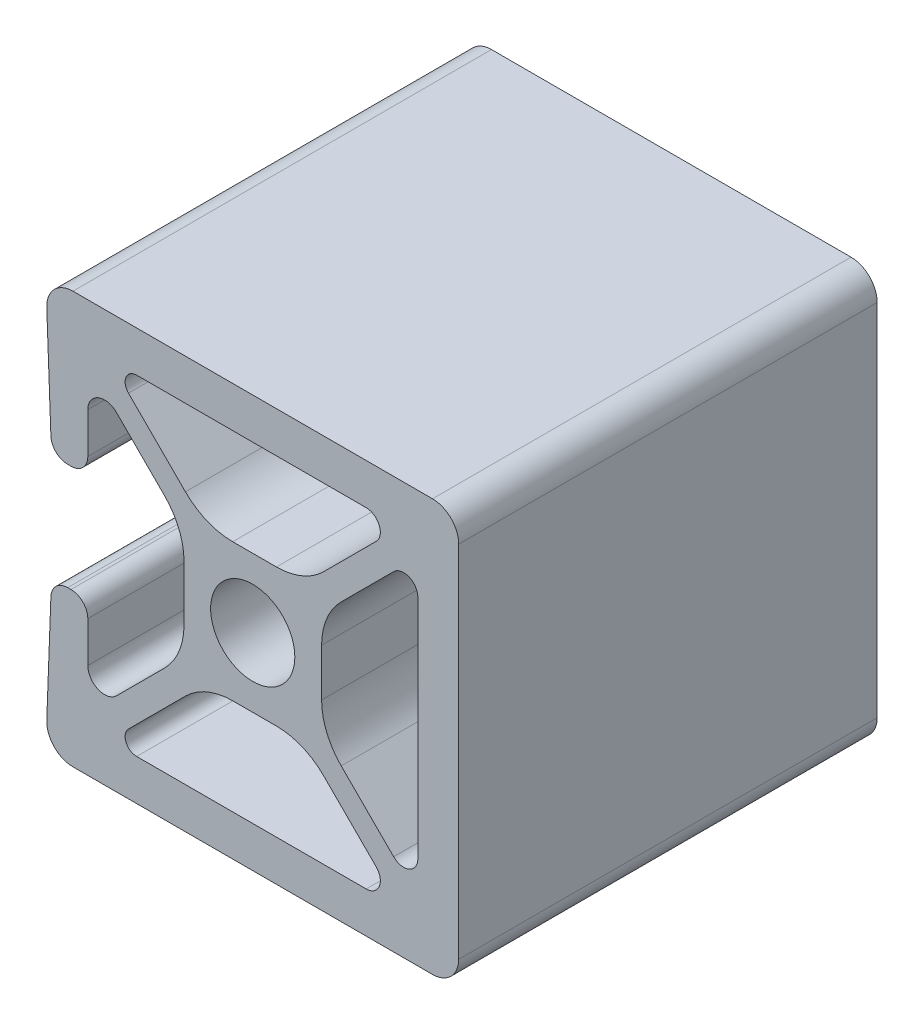
from build123d import *

# Parameters (mm, degrees)
EXTRUDE1_DEPTH = 25.4


with BuildPart() as part:
    # Sketch1 → Extrude1 (new body)
    with BuildSketch(Plane.XY):
        with BuildLine():
            Line((-8.268033791, 7.446247994), (-5.358427067, 4.536641271))
            ThreePointArc((-5.358427067, 4.536641271), (-4.478329805, 3.219482637), (-4.169280745, 1.665788092))
            Line((-4.169280745, 1.665788092), (-4.169280745, 0))
            Line((-4.169280745, 0), (-4.169280745, -1.665788092))
            ThreePointArc((-4.169280745, -1.665788092), (-4.478329805, -3.219482637), (-5.358427067, -4.536641271))
            Line((-5.358427067, -4.536641271), (-8.268033791, -7.446247994))
            ThreePointArc((-8.268033791, -7.446247994), (-9.379617585, -7.667355758), (-10.009279225, -6.72500052))
            Line((-10.009279225, -6.72500052), (-10.009279225, -4.25999656))
            ThreePointArc((-10.009279225, -4.25999656), (-10.308029711, -3.538749086), (-11.029277185, -3.2399986))
            Line((-11.029277185, -3.2399986), (-11.23000167, -3.2399986))
            ThreePointArc((-11.23000167, -3.2399986), (-11.937549497, -3.525304849), (-12.249277285, -4.221616108))
            Line((-12.249277285, -4.221616108), (-12.49887312, -10.850171322))
            ThreePointArc((-12.49887312, -10.850171322), (-12.055256326, -12.012943733), (-10.90999977, -12.49999913))
            Line((-10.90999977, -12.49999913), (0, -12.49999913))
            Line((0, -12.49999913), (10.90999977, -12.49999913))
            ThreePointArc((10.90999977, -12.49999913), (12.0342991, -12.0342991), (12.49999913, -10.90999977))
            Line((12.49999913, -10.90999977), (12.49999913, 10.90999977))
            ThreePointArc((12.49999913, 10.90999977), (12.0342991, 12.0342991), (10.90999977, 12.49999913))
            Line((10.90999977, 12.49999913), (0, 12.49999913))
            Line((0, 12.49999913), (-10.90999977, 12.49999913))
            ThreePointArc((-10.90999977, 12.49999913), (-12.055256326, 12.012943733), (-12.49887312, 10.850171322))
            Line((-12.49887312, 10.850171322), (-12.249277285, 4.221616108))
            ThreePointArc((-12.249277285, 4.221616108), (-11.937549497, 3.525304849), (-11.23000167, 3.2399986))
            Line((-11.23000167, 3.2399986), (-11.029277185, 3.2399986))
            ThreePointArc((-11.029277185, 3.2399986), (-10.308029711, 3.538749086), (-10.009279225, 4.25999656))
            Line((-10.009279225, 4.25999656), (-10.009279225, 6.72500052))
            ThreePointArc((-10.009279225, 6.72500052), (-9.379617585, 7.667355758), (-8.268033791, 7.446247994))
        make_face()
        with BuildLine():
            Line((-7.539973637, 8.825029193), (-4.084091296, 5.369146852))
            ThreePointArc((-4.084091296, 5.369146852), (-2.766932662, 4.48904959), (-1.213238118, 4.18000053))
            Line((-1.213238118, 4.18000053), (0, 4.18000053))
            Line((0, 4.18000053), (1.439511835, 4.18000053))
            ThreePointArc((1.439511835, 4.18000053), (2.993206379, 4.48904959), (4.310365013, 5.369146852))
            Line((4.310365013, 5.369146852), (7.493110816, 8.551892654))
            ThreePointArc((7.493110816, 8.551892654), (7.679535009, 9.489110364), (6.8850002, 10.02000155))
            Line((6.8850002, 10.02000155), (0, 10.02000155))
            Line((0, 10.02000155), (-7.04499988, 10.02000155))
            ThreePointArc((-7.04499988, 10.02000155), (-7.691714259, 9.587880817), (-7.539973637, 8.825029193))
        make_face(mode=Mode.SUBTRACT)
        with BuildLine():
            Line((0, -10.02000155), (-7.04499988, -10.02000155))
            ThreePointArc((-7.04499988, -10.02000155), (-7.691714259, -9.587880817), (-7.539973637, -8.825029193))
            Line((-7.539973637, -8.825029193), (-4.084091296, -5.369146852))
            ThreePointArc((-4.084091296, -5.369146852), (-2.766932662, -4.48904959), (-1.213238118, -4.18000053))
            Line((-1.213238118, -4.18000053), (0, -4.18000053))
            Line((0, -4.18000053), (1.439511835, -4.18000053))
            ThreePointArc((1.439511835, -4.18000053), (2.993206379, -4.48904959), (4.310365013, -5.369146852))
            Line((4.310365013, -5.369146852), (7.493110816, -8.551892654))
            ThreePointArc((7.493110816, -8.551892654), (7.679535009, -9.489110364), (6.8850002, -10.02000155))
            Line((6.8850002, -10.02000155), (0, -10.02000155))
        make_face(mode=Mode.SUBTRACT)
        with BuildLine():
            Line((8.551892654, 7.493110816), (5.369146852, 4.310365013))
            ThreePointArc((5.369146852, 4.310365013), (4.48904959, 2.993206379), (4.18000053, 1.439511835))
            Line((4.18000053, 1.439511835), (4.18000053, -1.439511835))
            ThreePointArc((4.18000053, -1.439511835), (4.48904959, -2.993206379), (5.369146852, -4.310365013))
            Line((5.369146852, -4.310365013), (8.551892654, -7.493110816))
            ThreePointArc((8.551892654, -7.493110816), (9.489110364, -7.679535009), (10.02000155, -6.8850002))
            Line((10.02000155, -6.8850002), (10.02000155, 6.8850002))
            ThreePointArc((10.02000155, 6.8850002), (9.489110364, 7.679535009), (8.551892654, 7.493110816))
        make_face(mode=Mode.SUBTRACT)
        with BuildLine():
            ThreePointArc((0, 2.55499997), (-1.806657805, 1.806657805), (-2.55499997, 0))
            ThreePointArc((-2.55499997, 0), (-1.806657805, -1.806657805), (0, -2.55499997))
            ThreePointArc((0, -2.55499997), (1.806657805, -1.806657805), (2.55499997, 0))
            ThreePointArc((2.55499997, 0), (1.806657805, 1.806657805), (0, 2.55499997))
        make_face(mode=Mode.SUBTRACT)
    extrude(amount=EXTRUDE1_DEPTH)


solid = part.part
